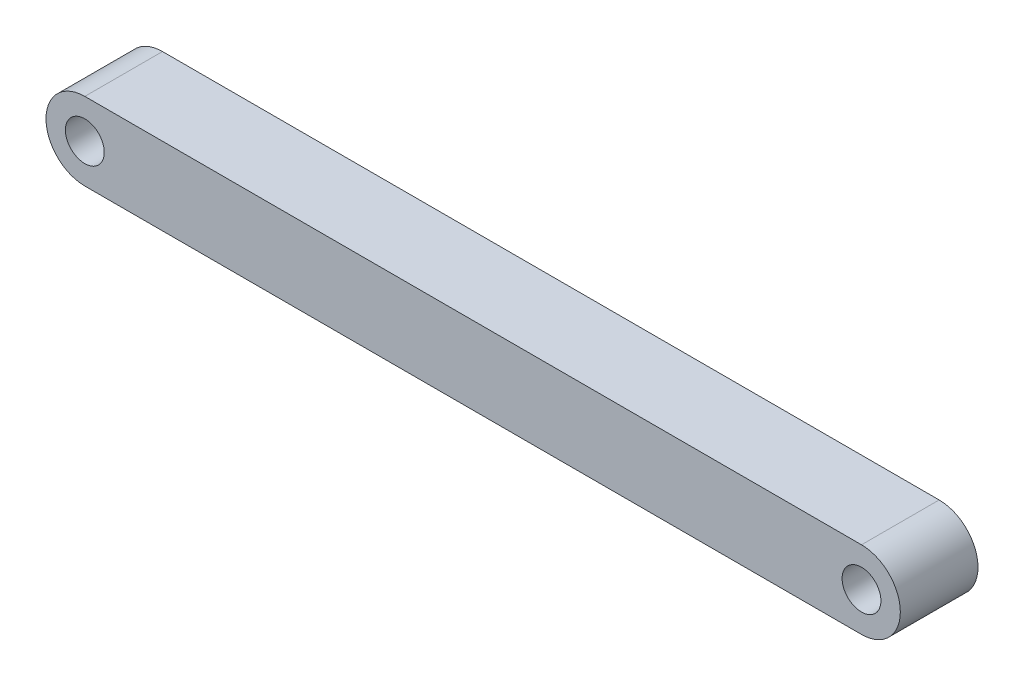
from build123d import *

# Parameters (mm, degrees)
SKETCH1_R           = 2.5
BOSS_EXTRUDE1_DEPTH = 10


with BuildPart() as part:
    # Sketch1 → Boss-Extrude1 (new body)
    with BuildSketch(Plane.XY):
        with BuildLine():
            Line((-50, 5), (50, 5))
            ThreePointArc((50, 5), (55, 0), (50, -5))
            Line((50, -5), (-50, -5))
            ThreePointArc((-50, -5), (-55, 0), (-50, 5))
        make_face()
        with Locations((-50, 0)):
            Circle(SKETCH1_R, mode=Mode.SUBTRACT)
        with Locations((50, 0)):
            Circle(SKETCH1_R, mode=Mode.SUBTRACT)
    extrude(amount=BOSS_EXTRUDE1_DEPTH)


solid = part.part
